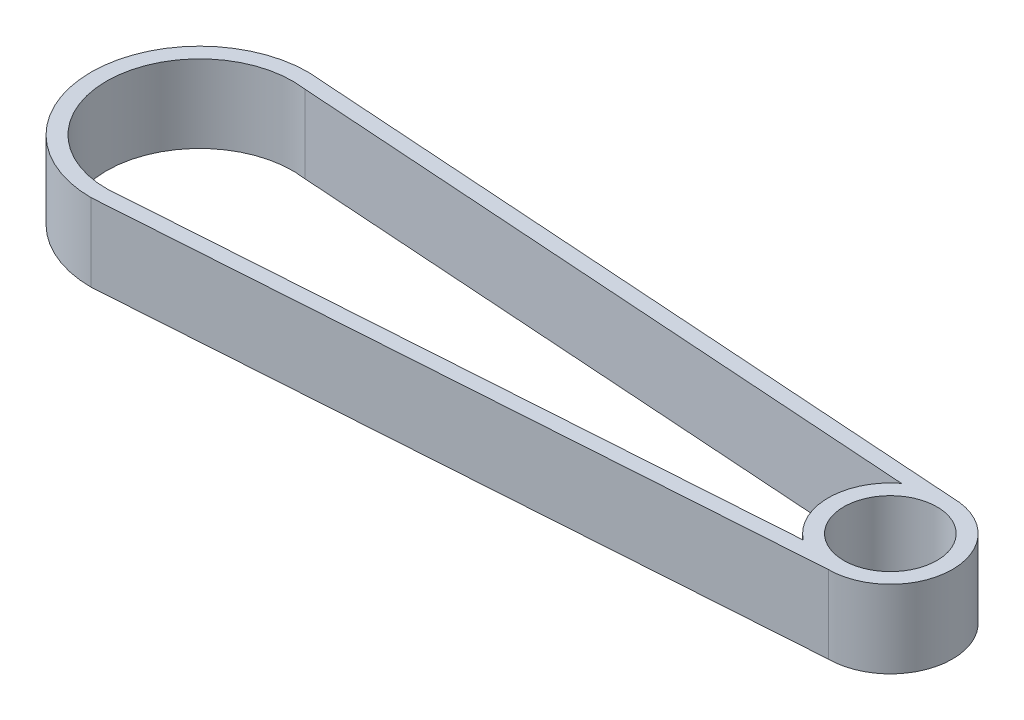
from build123d import *

# Parameters (mm, degrees)
SKETCH1_R           = 6
BOSS_EXTRUDE1_DEPTH = 10


with BuildPart() as part:
    # Sketch1 → Boss-Extrude1 (new body)
    with BuildSketch(Plane(origin=(0, 0, 0), x_dir=(1, 0, 0), z_dir=(0, 1, 0))):
        with BuildLine():
            ThreePointArc((0, 14), (-14, 0), (0, -14))
            Line((0, -14), (89, -8))
            ThreePointArc((89, -8), (97, 0), (89, 8))
            Line((89, 8), (0, 14))
        make_face()
        with BuildLine():
            ThreePointArc((1.674796148, -11.882552666), (0.807156628, -11.972823317), (-0.064748194, -11.999825318))
            ThreePointArc((-0.064748194, -11.999825318), (-12, 0), (-0.064748194, 11.999825318))
            ThreePointArc((-0.064748194, 11.999825318), (0.807156628, 11.972823317), (1.674796148, 11.882552666))
            Line((1.674796148, 11.882552666), (84.102414172, 6.325634597))
            ThreePointArc((84.102414172, 6.325634597), (81, 0), (84.102414172, -6.325634597))
            Line((84.102414172, -6.325634597), (1.674796148, -11.882552666))
        make_face(mode=Mode.SUBTRACT)
        with Locations((89, 0)):
            Circle(SKETCH1_R, mode=Mode.SUBTRACT)
    extrude(amount=BOSS_EXTRUDE1_DEPTH)


solid = part.part
